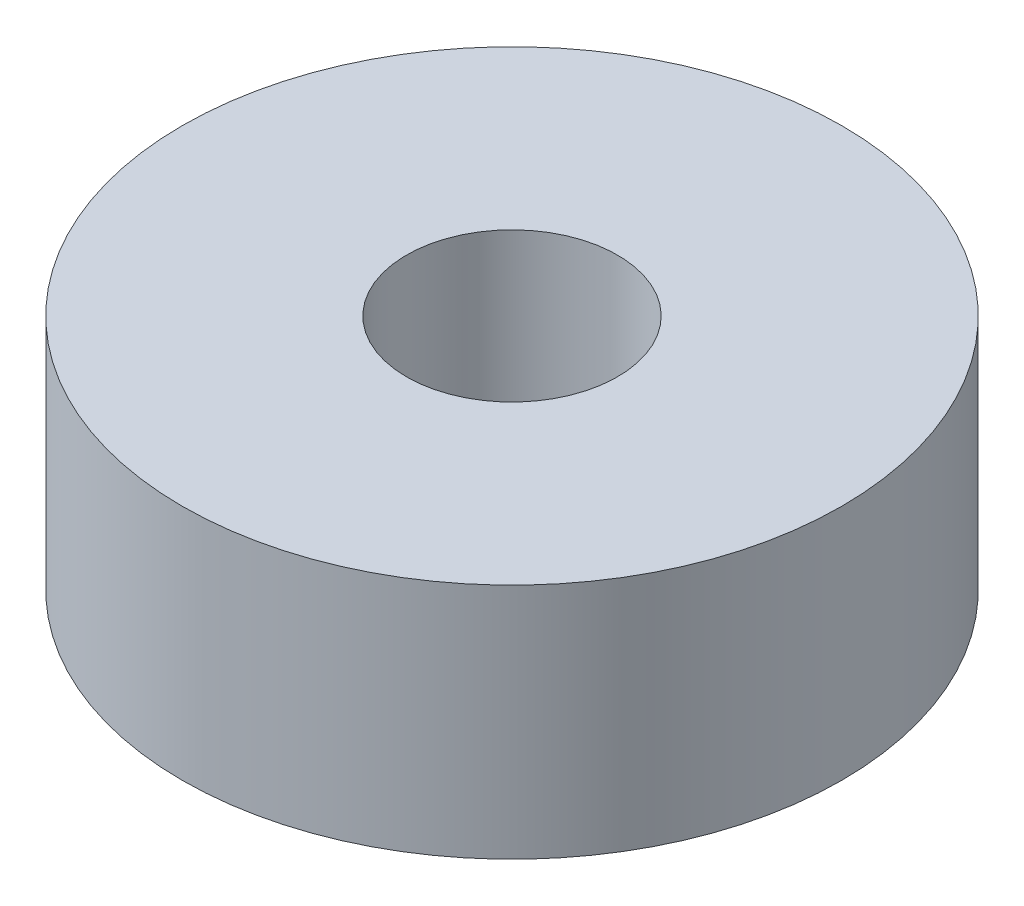
from build123d import *

# Parameters (mm, degrees)
SKETCH_1_R      = 25
SKETCH_1_R_2    = 8
EXTRUDE_1_DEPTH = 18


with BuildPart() as part:
    # 草图1 → 凸台-拉伸1 (new body)
    with BuildSketch(Plane(origin=(0, 0, 0), x_dir=(1, 0, 0), z_dir=(0, 1, 0))):
        Circle(SKETCH_1_R)
        Circle(SKETCH_1_R_2, mode=Mode.SUBTRACT)
    extrude(amount=EXTRUDE_1_DEPTH)


solid = part.part
